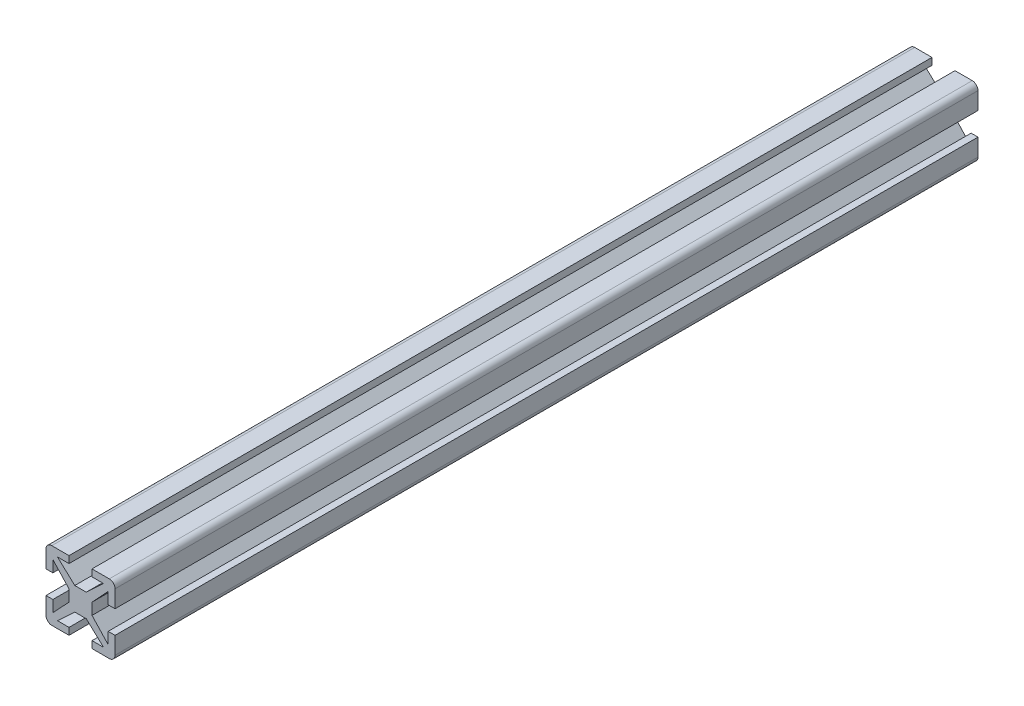
from build123d import *

# Parameters (mm, degrees)
EXTRUSION1_DEPTH             = 75
ENL_V_MAT_EXTRU_1_DEPTH      = 151.239808307
R_P_TITION_CIRCULAIRE1_COUNT = 4


with BuildPart() as part:
    # Esquisse1 → Extrusion1 (new, symmetric)
    with BuildSketch(Plane.XY):
        with BuildLine():
            Line((-6, 5), (-6, -5))
            ThreePointArc((-6, -5), (-5.707106781, -5.707106781), (-5, -6))
            Line((-5, -6), (5, -6))
            ThreePointArc((5, -6), (5.707106781, -5.707106781), (6, -5))
            Line((6, -5), (6, 5))
            ThreePointArc((6, 5), (5.707106781, 5.707106781), (5, 6))
            Line((5, 6), (-5, 6))
            ThreePointArc((-5, 6), (-5.707106781, 5.707106781), (-6, 5))
        make_face()
    extrude(amount=EXTRUSION1_DEPTH, both=True)

    # Esquisse3 → Enlèv. mat.-Extru.1 (cut, through all)
    with BuildSketch(Plane.XY.offset(75)):
        Polygon((6, 2), (4.8, 2), (4.8, 4), (2, 1), (2, -1), (4.8, -4), (4.8, -2), (6, -2), align=None)
    enl_v_mat_extru_1 = extrude(amount=-ENL_V_MAT_EXTRU_1_DEPTH, mode=Mode.SUBTRACT)

    # Répétition circulaire1: Enlèv. mat.-Extru.1 ×4 about axis
    r_p_tition_circulaire1_axis = Axis((0, 0, -1), (0, 0, 1))
    for i in range(1, R_P_TITION_CIRCULAIRE1_COUNT):
        add(enl_v_mat_extru_1.rotate(r_p_tition_circulaire1_axis, i * 360 / R_P_TITION_CIRCULAIRE1_COUNT), mode=Mode.SUBTRACT)


solid = part.part
